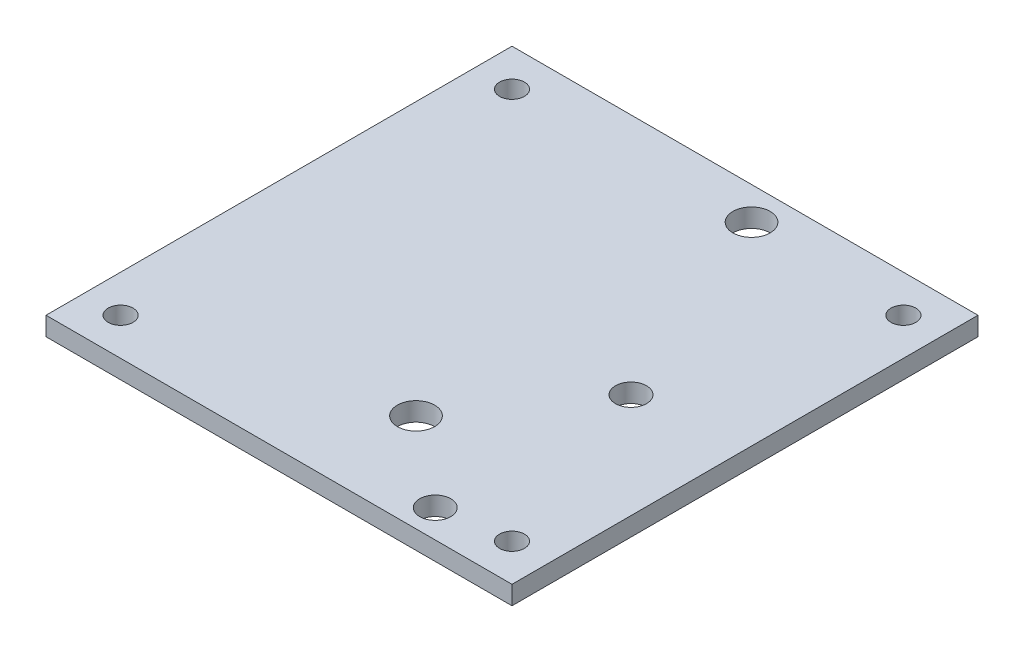
from build123d import *

# Parameters (mm, degrees)
SKETCH1_W           = 75
SKETCH1_H           = 75
SKETCH1_R           = 2
SKETCH1_R_2         = 2.5
SKETCH1_R_3         = 3
BOSS_EXTRUDE1_DEPTH = 3


with BuildPart() as part:
    # Sketch1 → Boss-Extrude1 (new body)
    with BuildSketch(Plane(origin=(0, 0, 0), x_dir=(1, 0, 0), z_dir=(0, 1, 0))):
        Rectangle(SKETCH1_W, SKETCH1_H)
        with Locations((31.5, 31.5)):
            Circle(SKETCH1_R, mode=Mode.SUBTRACT)
        with Locations((31.5, -31.5)):
            Circle(SKETCH1_R, mode=Mode.SUBTRACT)
        with Locations((-31.5, -31.5)):
            Circle(SKETCH1_R, mode=Mode.SUBTRACT)
        with Locations((-31.5, 31.5)):
            Circle(SKETCH1_R, mode=Mode.SUBTRACT)
        with Locations((20.65, -33)):
            Circle(SKETCH1_R_2, mode=Mode.SUBTRACT)
        with Locations((20.65, -1.5)):
            Circle(SKETCH1_R_2, mode=Mode.SUBTRACT)
        with Locations((6.3, 32.25)):
            Circle(SKETCH1_R_3, mode=Mode.SUBTRACT)
        with Locations((6.3, -21.75)):
            Circle(SKETCH1_R_3, mode=Mode.SUBTRACT)
    extrude(amount=BOSS_EXTRUDE1_DEPTH)


solid = part.part
